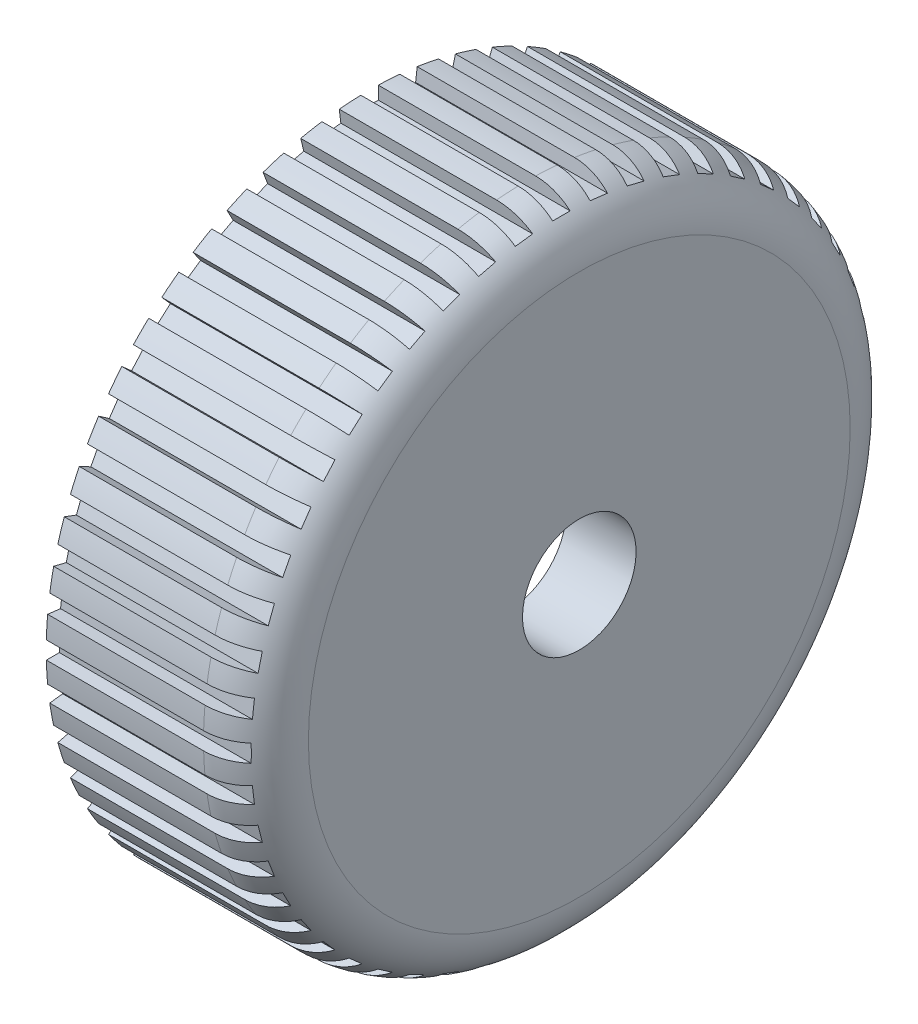
from build123d import *

# Parameters (mm, degrees)
SKETCH_2_W          = 2
SKETCH_2_H          = 3
SKETCH_2_W_2        = 3
SKETCH_2_H_2        = 2
CUT_EXTRUDE_2_DEPTH = 25


with BuildPart() as part:
    # Эскиз1 → Повернуть1 (revolve)
    with BuildSketch(Plane.XY):
        with BuildLine():
            Line((0, 37), (0, 30.3))
            Line((0, 30.3), (16, 30.3))
            Line((16, 30.3), (16, 6.5))
            Line((16, 6.5), (24, 6.5))
            Line((24, 6.5), (24, 31))
            ThreePointArc((24, 31), (22.242640687, 35.242640687), (18, 37))
            Line((18, 37), (0, 37))
        make_face()
    revolve(axis=Axis((0, 0, 0), (1, 0, 0)))

    # Эскиз2 → Вырез-Вытянуть2 (cut, through all)
    with BuildSketch(Plane.ZY):
        with Locations((0, 37)):
            Rectangle(SKETCH_2_W, SKETCH_2_H)
        Polygon((5.633371064, 38.098754973), (5.271761023, 35.12062835), (3.286343275, 35.361701711), (3.647953316, 38.339828333), align=None)
        Polygon((10.184594892, 37.141944307), (9.4666479, 34.229118854), (7.524764265, 34.707750183), (8.242711258, 37.620575635), align=None)
        Polygon((14.587304394, 35.643520456), (13.523489733, 32.838471728), (11.653457247, 33.547681502), (12.717271908, 36.35273023), align=None)
        Polygon((18.777298149, 33.625333816), (17.383128633, 30.968965739), (15.612216582, 31.898412083), (17.006386098, 34.55478016), align=None)
        Polygon((22.693476615, 31.11681409), (20.989282375, 28.647862492), (19.343314643, 29.783991986), (21.047508883, 32.252943584), align=None)
        Polygon((26.27873309, 28.154541146), (24.289365116, 25.909008902), (22.792343619, 27.235254218), (24.781711594, 29.480786463), align=None)
        Polygon((29.480786463, 24.781711594), (27.235254218, 22.792343619), (25.909008902, 24.289365116), (28.154541146, 26.27873309), align=None)
        Polygon((32.252943584, 21.047508883), (29.783991986, 19.343314643), (28.647862492, 20.989282375), (31.11681409, 22.693476615), align=None)
        Polygon((34.55478016, 17.006386098), (31.898412083, 15.612216582), (30.968965739, 17.383128633), (33.625333816, 18.777298149), align=None)
        Polygon((36.35273023, 12.717271908), (33.547681502, 11.653457247), (32.838471728, 13.523489733), (35.643520456, 14.587304394), align=None)
        Polygon((37.620575635, 8.242711258), (34.707750183, 7.524764265), (34.229118854, 9.4666479), (37.141944307, 10.184594892), align=None)
        Polygon((38.339828333, 3.647953316), (35.361701711, 3.286343275), (35.12062835, 5.271761023), (38.098754973, 5.633371064), align=None)
        with Locations((37, 0)):
            Rectangle(SKETCH_2_W_2, SKETCH_2_H_2)
        Polygon((38.098754973, -5.633371064), (35.12062835, -5.271761023), (35.361701711, -3.286343275), (38.339828333, -3.647953316), align=None)
        Polygon((37.141944307, -10.184594892), (34.229118854, -9.4666479), (34.707750183, -7.524764265), (37.620575635, -8.242711258), align=None)
        Polygon((35.643520456, -14.587304394), (32.838471728, -13.523489733), (33.547681502, -11.653457247), (36.35273023, -12.717271908), align=None)
        Polygon((33.625333816, -18.777298149), (30.968965739, -17.383128633), (31.898412083, -15.612216582), (34.55478016, -17.006386098), align=None)
        Polygon((31.11681409, -22.693476615), (28.647862492, -20.989282375), (29.783991986, -19.343314643), (32.252943584, -21.047508883), align=None)
        Polygon((28.154541146, -26.27873309), (25.909008902, -24.289365116), (27.235254218, -22.792343619), (29.480786463, -24.781711594), align=None)
        Polygon((24.781711594, -29.480786463), (22.792343619, -27.235254218), (24.289365116, -25.909008902), (26.27873309, -28.154541146), align=None)
        Polygon((21.047508883, -32.252943584), (19.343314643, -29.783991986), (20.989282375, -28.647862492), (22.693476615, -31.11681409), align=None)
        Polygon((17.006386098, -34.55478016), (15.612216582, -31.898412083), (17.383128633, -30.968965739), (18.777298149, -33.625333816), align=None)
        Polygon((12.717271908, -36.35273023), (11.653457247, -33.547681502), (13.523489733, -32.838471728), (14.587304394, -35.643520456), align=None)
        Polygon((8.242711258, -37.620575635), (7.524764265, -34.707750183), (9.4666479, -34.229118854), (10.184594892, -37.141944307), align=None)
        Polygon((3.647953316, -38.339828333), (3.286343275, -35.361701711), (5.271761023, -35.12062835), (5.633371064, -38.098754973), align=None)
        with Locations((0, -37)):
            Rectangle(SKETCH_2_W, SKETCH_2_H)
        Polygon((-5.633371064, -38.098754973), (-5.271761023, -35.12062835), (-3.286343275, -35.361701711), (-3.647953316, -38.339828333), align=None)
        Polygon((-10.184594892, -37.141944307), (-9.4666479, -34.229118854), (-7.524764265, -34.707750183), (-8.242711258, -37.620575635), align=None)
        Polygon((-14.587304394, -35.643520456), (-13.523489733, -32.838471728), (-11.653457247, -33.547681502), (-12.717271908, -36.35273023), align=None)
        Polygon((-18.777298149, -33.625333816), (-17.383128633, -30.968965739), (-15.612216582, -31.898412083), (-17.006386098, -34.55478016), align=None)
        Polygon((-22.693476615, -31.11681409), (-20.989282375, -28.647862492), (-19.343314643, -29.783991986), (-21.047508883, -32.252943584), align=None)
        Polygon((-26.27873309, -28.154541146), (-24.289365116, -25.909008902), (-22.792343619, -27.235254218), (-24.781711594, -29.480786463), align=None)
        Polygon((-29.480786463, -24.781711594), (-27.235254218, -22.792343619), (-25.909008902, -24.289365116), (-28.154541146, -26.27873309), align=None)
        Polygon((-32.252943584, -21.047508883), (-29.783991986, -19.343314643), (-28.647862492, -20.989282375), (-31.11681409, -22.693476615), align=None)
        Polygon((-34.55478016, -17.006386098), (-31.898412083, -15.612216582), (-30.968965739, -17.383128633), (-33.625333816, -18.777298149), align=None)
        Polygon((-36.35273023, -12.717271908), (-33.547681502, -11.653457247), (-32.838471728, -13.523489733), (-35.643520456, -14.587304394), align=None)
        Polygon((-37.620575635, -8.242711258), (-34.707750183, -7.524764265), (-34.229118854, -9.4666479), (-37.141944307, -10.184594892), align=None)
        Polygon((-38.339828333, -3.647953316), (-35.361701711, -3.286343275), (-35.12062835, -5.271761023), (-38.098754973, -5.633371064), align=None)
        with Locations((-37, 0)):
            Rectangle(SKETCH_2_W_2, SKETCH_2_H_2)
        Polygon((-38.098754973, 5.633371064), (-35.12062835, 5.271761023), (-35.361701711, 3.286343275), (-38.339828333, 3.647953316), align=None)
        Polygon((-37.141944307, 10.184594892), (-34.229118854, 9.4666479), (-34.707750183, 7.524764265), (-37.620575635, 8.242711258), align=None)
        Polygon((-35.643520456, 14.587304394), (-32.838471728, 13.523489733), (-33.547681502, 11.653457247), (-36.35273023, 12.717271908), align=None)
        Polygon((-33.625333816, 18.777298149), (-30.968965739, 17.383128633), (-31.898412083, 15.612216582), (-34.55478016, 17.006386098), align=None)
        Polygon((-31.11681409, 22.693476615), (-28.647862492, 20.989282375), (-29.783991986, 19.343314643), (-32.252943584, 21.047508883), align=None)
        Polygon((-28.154541146, 26.27873309), (-25.909008902, 24.289365116), (-27.235254218, 22.792343619), (-29.480786463, 24.781711594), align=None)
        Polygon((-24.781711594, 29.480786463), (-22.792343619, 27.235254218), (-24.289365116, 25.909008902), (-26.27873309, 28.154541146), align=None)
        Polygon((-21.047508883, 32.252943584), (-19.343314643, 29.783991986), (-20.989282375, 28.647862492), (-22.693476615, 31.11681409), align=None)
        Polygon((-17.006386098, 34.55478016), (-15.612216582, 31.898412083), (-17.383128633, 30.968965739), (-18.777298149, 33.625333816), align=None)
        Polygon((-12.717271908, 36.35273023), (-11.653457247, 33.547681502), (-13.523489733, 32.838471728), (-14.587304394, 35.643520456), align=None)
        Polygon((-8.242711258, 37.620575635), (-7.524764265, 34.707750183), (-9.4666479, 34.229118854), (-10.184594892, 37.141944307), align=None)
        Polygon((-3.647953316, 38.339828333), (-3.286343275, 35.361701711), (-5.271761023, 35.12062835), (-5.633371064, 38.098754973), align=None)
    extrude(amount=-CUT_EXTRUDE_2_DEPTH, mode=Mode.SUBTRACT)


solid = part.part
